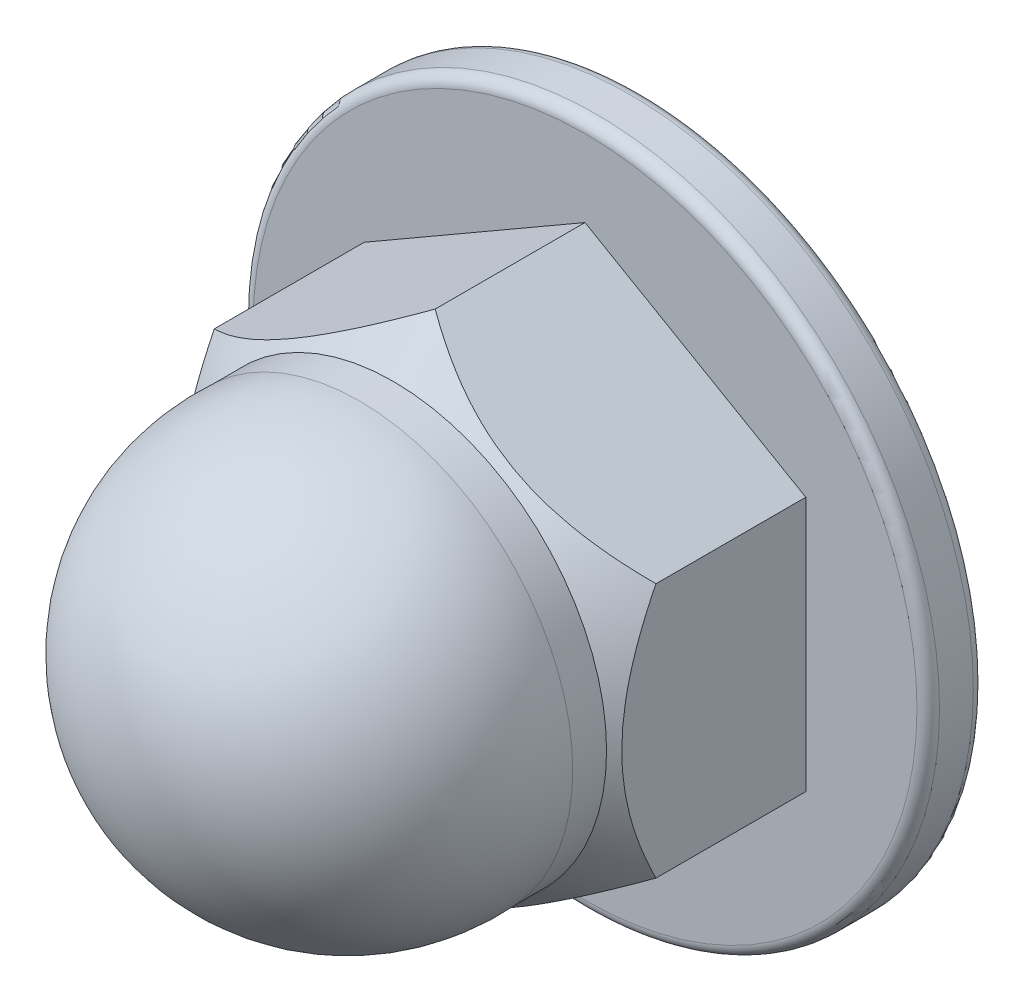
from build123d import *

# Parameters (mm, degrees)
SKETCH1_R           = 30.453013084
BOSS_EXTRUDE1_DEPTH = 5
BOSS_EXTRUDE2_DEPTH = 17
SKETCH3_R           = 36.437835874
SKETCH3_R_2         = 18.912930376
CUT_EXTRUDE1_DEPTH  = 17
CUT_EXTRUDE1_TAPER  = 45
SKETCH4_R           = 18.912930376
BOSS_EXTRUDE3_DEPTH = 3
DOME1_FACE_RADIUS   = 18.912930376
DOME1_HEIGHT        = 20
FILLET1_R           = 1
FILLET2_R           = 1


with BuildPart() as part:
    # Sketch1 → Boss-Extrude1 (new body)
    with BuildSketch(Plane.XY):
        Circle(SKETCH1_R)
    extrude(amount=BOSS_EXTRUDE1_DEPTH)

    # Sketch2 → Boss-Extrude2 (add)
    with BuildSketch(Plane.XY.offset(5)):
        Polygon((0, 22.618579174), (-19.588264162, 11.309289587), (-19.588264162, -11.309289587), (0, -22.618579174), (19.588264162, -11.309289587), (19.588264162, 11.309289587), align=None)
    extrude(amount=BOSS_EXTRUDE2_DEPTH)

    # Sketch3 → Cut-Extrude1 (cut)
    with BuildSketch(Plane.XY.offset(22)):
        Circle(SKETCH3_R)
        Circle(SKETCH3_R_2, mode=Mode.SUBTRACT)
    extrude(amount=-CUT_EXTRUDE1_DEPTH, taper=CUT_EXTRUDE1_TAPER, mode=Mode.SUBTRACT)

    # Sketch4 → Boss-Extrude3 (add)
    with BuildSketch(Plane.XY.offset(22)):
        Circle(SKETCH4_R)
    extrude(amount=BOSS_EXTRUDE3_DEPTH)

    # Dome1: a dome of height H over a round flat face of radius A is a cap of a sphere of radius (A * A + H * H) / (2 * H)
    dome1_r = (DOME1_FACE_RADIUS * DOME1_FACE_RADIUS + DOME1_HEIGHT * DOME1_HEIGHT) / (2 * DOME1_HEIGHT)
    dome1_base = Plane((0, 0, 25), z_dir=(0, 0, 1))
    with Locations(dome1_base.offset(DOME1_HEIGHT - dome1_r)):
        dome1_ball = Sphere(dome1_r, mode=Mode.PRIVATE)
    add(split(dome1_ball, bisect_by=dome1_base, keep=Keep.TOP, mode=Mode.PRIVATE))

    # Fillet1
    fillet1_edges = [part.edges().sort_by_distance(p)[0] for p in [
        (-30.453013084, 0, 5),
    ]]
    fillet(fillet1_edges, radius=FILLET1_R)

    # Fillet2
    fillet2_edges = [part.edges().sort_by_distance(p)[0] for p in [
        (-30.453013084, 0, 0),
    ]]
    fillet(fillet2_edges, radius=FILLET2_R)


solid = part.part
